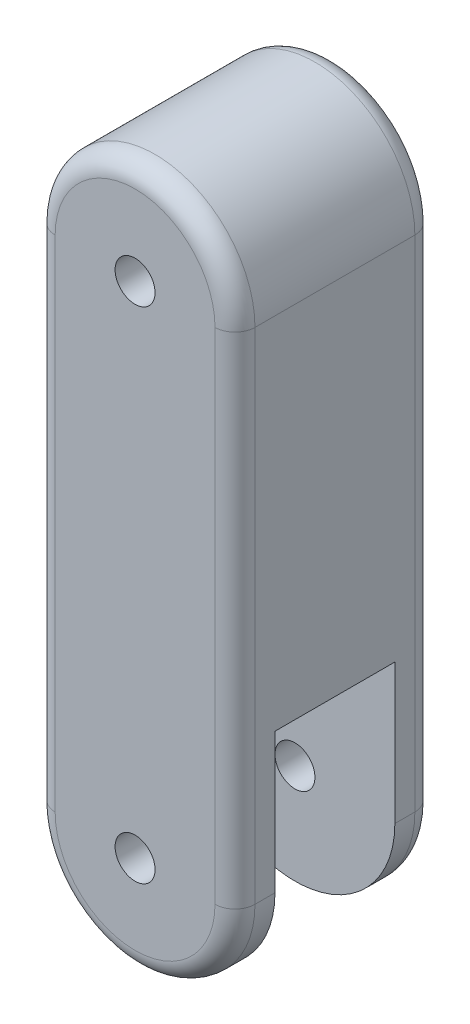
from build123d import *

# Parameters (mm, degrees)
CROQUIS1_R              = 0.5
SALIENTE_EXTRUIR2_DEPTH = 5
CROQUIS3_W              = 3
CROQUIS3_H              = 3.5
CROQUIS3_H_2            = 3.121183209
CORTAR_EXTRUIR2_DEPTH   = 5
REDONDEO1_R             = 0.5
REDONDEO2_R             = 0.5


with BuildPart() as part:
    # Croquis1 → Saliente-Extruir2 (new body)
    with BuildSketch(Plane.XY):
        with BuildLine():
            Line((-2.5, 0), (-2.5, -12.5))
            ThreePointArc((-2.5, -12.5), (0, -15), (2.5, -12.5))
            Line((2.5, -12.5), (2.5, 0))
            ThreePointArc((2.5, 0), (0, 2.5), (-2.5, 0))
        make_face()
        Circle(CROQUIS1_R, mode=Mode.SUBTRACT)
        with Locations((0, -12.5)):
            Circle(CROQUIS1_R, mode=Mode.SUBTRACT)
    extrude(amount=SALIENTE_EXTRUIR2_DEPTH)

    # Croquis3 → Cortar-Extruir2 (cut)
    with BuildSketch(Plane(origin=(2.5, 0, 0), x_dir=(0, 0, -1), z_dir=(1, 0, 0))):
        with Locations((-2.5, -10.75)):
            Rectangle(CROQUIS3_W, CROQUIS3_H)
        with Locations((-2.5, -14.060591605)):
            Rectangle(CROQUIS3_W, CROQUIS3_H_2)
    extrude(amount=-CORTAR_EXTRUIR2_DEPTH, mode=Mode.SUBTRACT)

    # Redondeo1
    redondeo1_edges = [part.edges().sort_by_distance(p)[0] for p in [
        (-2.5, -6.25, 5),
        (0, -15, 5),
        (2.5, -6.25, 5),
        (0, 2.5, 5),
    ]]
    fillet(redondeo1_edges, radius=REDONDEO1_R)

    # Redondeo2
    redondeo2_edges = [part.edges().sort_by_distance(p)[0] for p in [
        (-2.5, -6.25, 0),
        (0, 2.5, 0),
        (2.5, -6.25, 0),
        (0, -15, 0),
    ]]
    fillet(redondeo2_edges, radius=REDONDEO2_R)


solid = part.part
